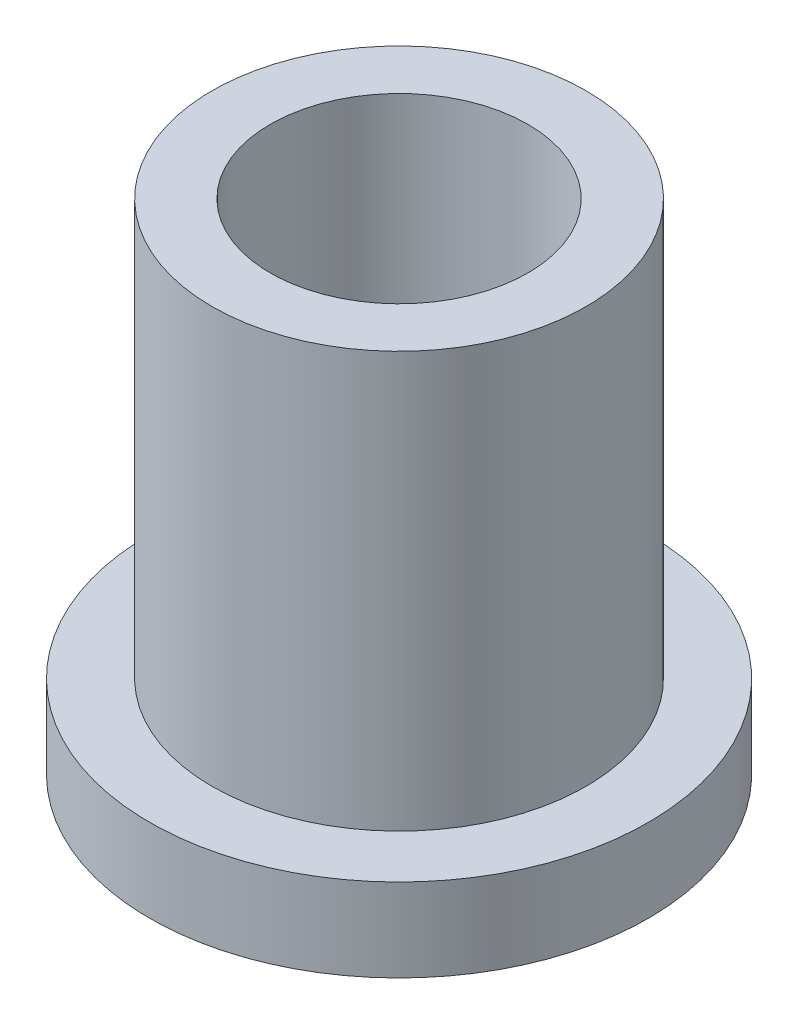
from build123d import *


with BuildPart() as part:
    # Эскиз1 → Повернуть1 (revolve)
    with BuildSketch(Plane.XY):
        Polygon((1.55, 6), (1.55, 0), (3, 0), (3, 1), (2.25, 1), (2.25, 6), align=None)
    revolve(axis=Axis((0, 0, 0), (0, 1, 0)))


solid = part.part
